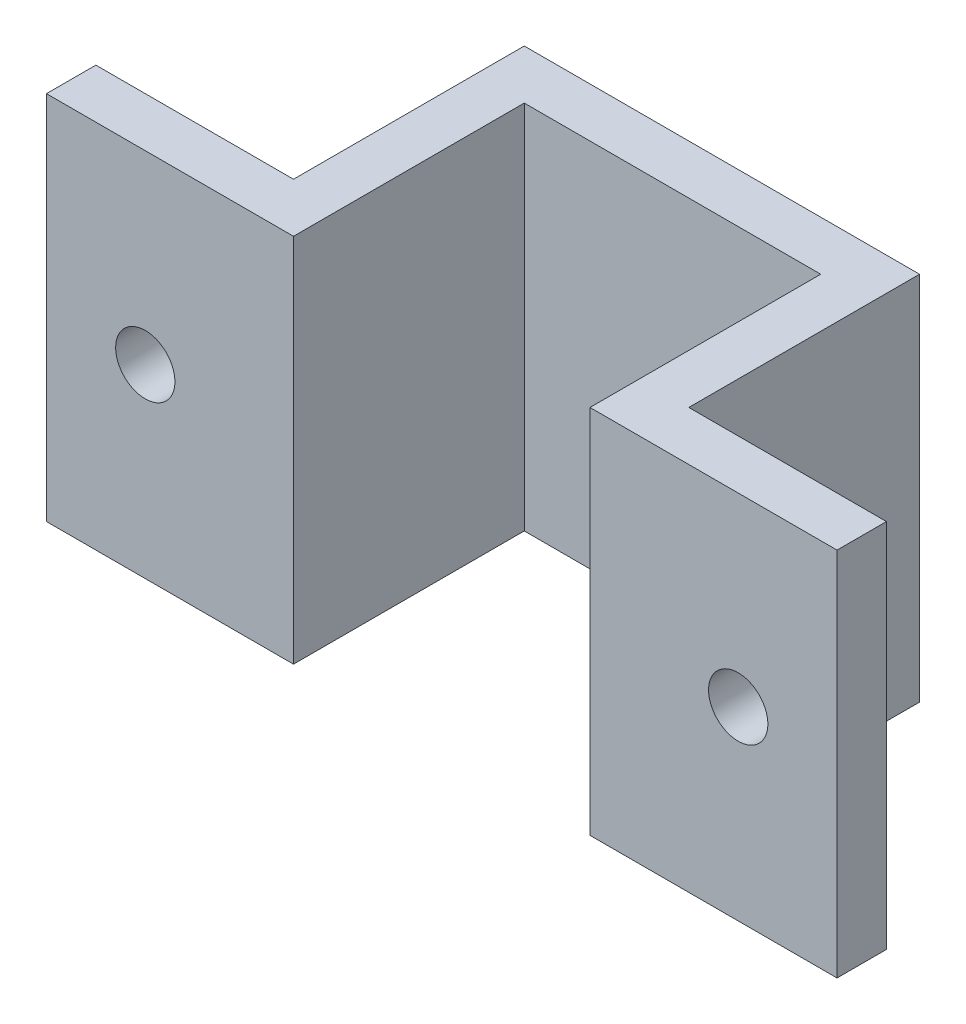
from build123d import *

# Parameters (mm, degrees)
BOSS_EXTRUDE1_DEPTH = 19.05
SKETCH2_R           = 1.524
CUT_EXTRUDE1_DEPTH  = 3.54


with BuildPart() as part:
    # Sketch1 → Boss-Extrude1 (new body)
    with BuildSketch(Plane(origin=(0, 0, 0), x_dir=(1, 0, 0), z_dir=(0, 1, 0))):
        Polygon((7.62, 0), (20.32, 0), (20.32, 2.54), (10.16, 2.54), (10.16, 14.4018), (-10.16, 14.4018), (-10.16, 2.54), (-20.32, 2.54), (-20.32, 0), (-7.62, 0), (-7.62, 11.8618), (7.62, 11.8618), align=None)
    extrude(amount=BOSS_EXTRUDE1_DEPTH)

    # Sketch2 → Cut-Extrude1 (cut, through all)
    with BuildSketch(Plane(origin=(0, 0, -2.54), x_dir=(-1, 0, 0), z_dir=(0, 0, -1))):
        with Locations((15.24, 9.525)):
            Circle(SKETCH2_R)
        with Locations((-15.24, 9.525)):
            Circle(SKETCH2_R)
    extrude(amount=-CUT_EXTRUDE1_DEPTH, mode=Mode.SUBTRACT)


solid = part.part
